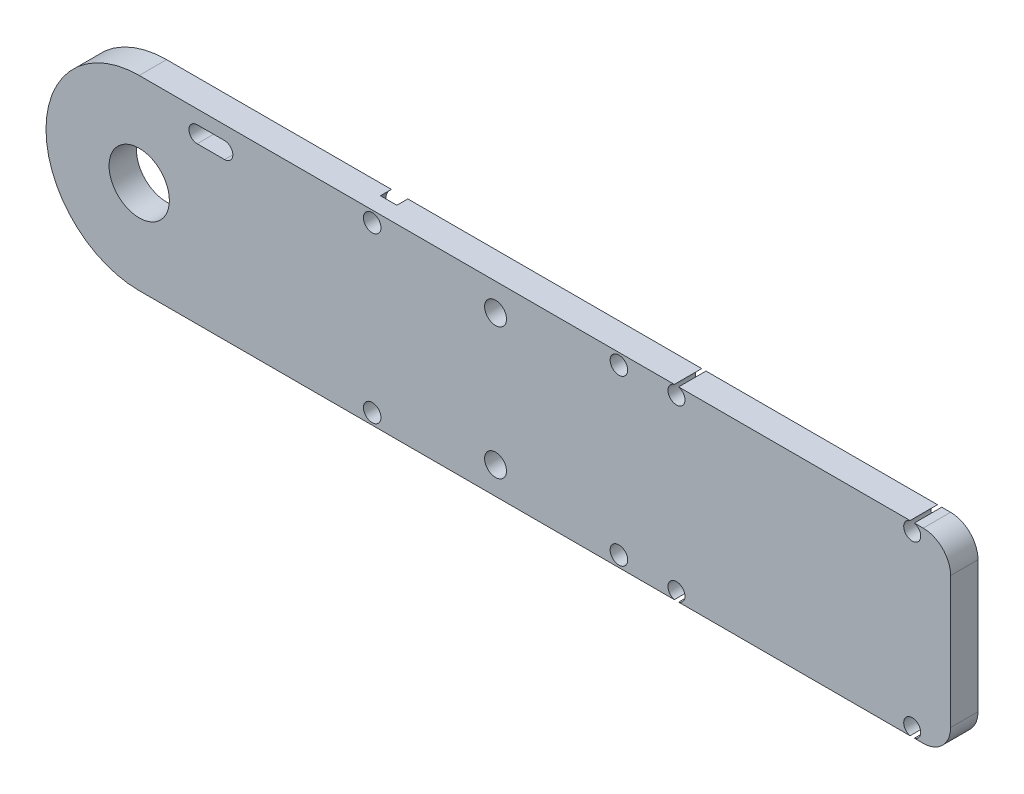
from build123d import *

# Parameters (mm, degrees)
SKETCH2_R           = 5.5
BOSS_EXTRUDE1_DEPTH = 2.5
FILLET1_R           = 5
SKETCH3_R           = 1.6
SKETCH3_R_2         = 2
CUT_EXTRUDE1_DEPTH  = 150.057036063
SKETCH3_4_R         = 1.6
SKETCH3_4_R_2       = 2
CUT_EXTRUDE2_DEPTH  = 10
SKETCH4_R           = 2.5
CUT_EXTRUDE3_DEPTH  = 2


with BuildPart() as part:
    # Sketch2 → Boss-Extrude1 (new, symmetric)
    with BuildSketch(Plane.XY):
        with BuildLine():
            Line((148, 17), (0, 17))
            ThreePointArc((0, 17), (-17, 0), (0, -17))
            Line((0, -17), (148, -17))
            Line((148, -17), (148, 17))
        make_face()
        Circle(SKETCH2_R, mode=Mode.SUBTRACT)
    extrude(amount=BOSS_EXTRUDE1_DEPTH, both=True)

    # Fillet1
    fillet1_edges = [part.edges().sort_by_distance(p)[0] for p in [
        (148, -17, 0),
        (148, 17, 0),
    ]]
    fillet(fillet1_edges, radius=FILLET1_R)

    # Sketch3 → Cut-Extrude1 (cut, through all)
    with BuildSketch(Plane(origin=(0, 0, -2.5), x_dir=(-1, 0, 0), z_dir=(0, 0, -1))):
        with BuildLine():
            Line((-97.609487516, 17), (-98.390512484, 17))
            ThreePointArc((-98.390512484, 17), (-99.537449186, 15.303149803), (-98, 13.95))
            ThreePointArc((-98, 13.95), (-96.462550814, 15.303149803), (-97.609487516, 17))
        make_face()
        with BuildLine():
            ThreePointArc((-141.390512484, 17), (-141, 13.95), (-140.609487516, 17))
            Line((-140.609487516, 17), (-141.390512484, 17))
        make_face()
        with Locations((-87.5, 15)):
            Circle(SKETCH3_R)
        with Locations((-65, 12)):
            Circle(SKETCH3_R_2)
        with BuildLine():
            Line((-141.390512484, -17), (-140.609487516, -17))
            ThreePointArc((-140.609487516, -17), (-141, -13.95), (-141.390512484, -17))
        make_face()
        with BuildLine():
            ThreePointArc((-97.609487516, -17), (-98, -13.95), (-98.390512484, -17))
            Line((-98.390512484, -17), (-97.609487516, -17))
        make_face()
        with BuildLine():
            Line((-10.574175964, 14.5), (-15.574175964, 14.5))
            ThreePointArc((-15.574175964, 14.5), (-17.074175964, 13), (-15.574175964, 11.5))
            Line((-15.574175964, 11.5), (-10.574175964, 11.5))
            ThreePointArc((-10.574175964, 11.5), (-9.074175964, 13), (-10.574175964, 14.5))
        make_face()
        with Locations((-87.5, -15)):
            Circle(SKETCH3_R)
        with Locations((-65, -12)):
            Circle(SKETCH3_R_2)
    extrude(amount=-CUT_EXTRUDE1_DEPTH, mode=Mode.SUBTRACT)

    # Sketch3_4 → Cut-Extrude2 (cut)
    with BuildSketch(Plane(origin=(0, 0, -2.5), x_dir=(-1, 0, 0), z_dir=(0, 0, -1))):
        with BuildLine():
            Line((-97.609487516, 17), (-98.390512484, 17))
            ThreePointArc((-98.390512484, 17), (-99.537449186, 15.303149803), (-98, 13.95))
            ThreePointArc((-98, 13.95), (-96.462550814, 15.303149803), (-97.609487516, 17))
        make_face()
        with BuildLine():
            ThreePointArc((-141.390512484, 17), (-141, 13.95), (-140.609487516, 17))
            Line((-140.609487516, 17), (-141.390512484, 17))
        make_face()
        with Locations((-87.5, 15)):
            Circle(SKETCH3_4_R)
        with Locations((-65, 12)):
            Circle(SKETCH3_4_R_2)
        with BuildLine():
            Line((-141.390512484, -17), (-140.609487516, -17))
            ThreePointArc((-140.609487516, -17), (-141, -13.95), (-141.390512484, -17))
        make_face()
        with BuildLine():
            ThreePointArc((-97.609487516, -17), (-98, -13.95), (-98.390512484, -17))
            Line((-98.390512484, -17), (-97.609487516, -17))
        make_face()
        with BuildLine():
            Line((-10.574175964, 14.5), (-15.574175964, 14.5))
            ThreePointArc((-15.574175964, 14.5), (-17.074175964, 13), (-15.574175964, 11.5))
            Line((-15.574175964, 11.5), (-10.574175964, 11.5))
            ThreePointArc((-10.574175964, 11.5), (-9.074175964, 13), (-10.574175964, 14.5))
        make_face()
        with Locations((-87.5, -15)):
            Circle(SKETCH3_4_R)
        with Locations((-42.5, -15)):
            Circle(SKETCH3_4_R)
        with Locations((-42.5, 15)):
            Circle(SKETCH3_4_R)
        with Locations((-65, -12)):
            Circle(SKETCH3_4_R_2)
    extrude(amount=-CUT_EXTRUDE2_DEPTH, mode=Mode.SUBTRACT)

    # Sketch4 → Cut-Extrude3 (cut)
    with BuildSketch(Plane(origin=(0, 0, -2.5), x_dir=(-1, 0, 0), z_dir=(0, 0, -1))):
        with Locations((-42.5, 15)):
            Circle(SKETCH4_R)
        with Locations((-42.5, -15)):
            Circle(SKETCH4_R)
    extrude(amount=-CUT_EXTRUDE3_DEPTH, mode=Mode.SUBTRACT)


solid = part.part
